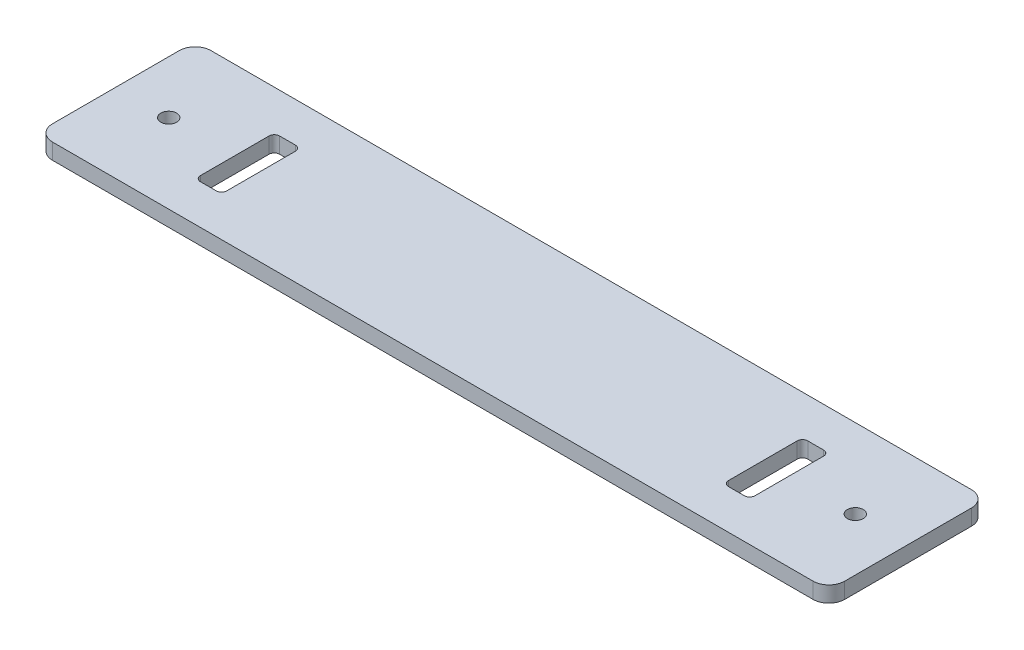
from build123d import *

# Parameters (mm, degrees)
SKETCH1_R           = 1.5
BOSS_EXTRUDE1_DEPTH = 3


with BuildPart() as part:
    # Sketch1 → Boss-Extrude1 (new body)
    with BuildSketch(Plane(origin=(0, 0, 0), x_dir=(1, 0, 0), z_dir=(0, 1, 0))):
        with BuildLine():
            Line((72, 15), (-72, 15))
            ThreePointArc((-72, 15), (-74.121320344, 14.121320344), (-75, 12))
            Line((-75, 12), (-75, -12))
            ThreePointArc((-75, -12), (-74.121320344, -14.121320344), (-72, -15))
            Line((-72, -15), (72, -15))
            ThreePointArc((72, -15), (74.121320344, -14.121320344), (75, -12))
            Line((75, -12), (75, 12))
            ThreePointArc((75, 12), (74.121320344, 14.121320344), (72, 15))
        make_face()
        with Locations((65, 0)):
            Circle(SKETCH1_R, mode=Mode.SUBTRACT)
        with Locations((-65, 0)):
            Circle(SKETCH1_R, mode=Mode.SUBTRACT)
        with BuildLine():
            Line((51.5, -7.5), (48.5, -7.5))
            ThreePointArc((48.5, -7.5), (47.792893219, -7.207106781), (47.5, -6.5))
            Line((47.5, -6.5), (47.5, 6.5))
            ThreePointArc((47.5, 6.5), (47.792893219, 7.207106781), (48.5, 7.5))
            Line((48.5, 7.5), (51.5, 7.5))
            ThreePointArc((51.5, 7.5), (52.207106781, 7.207106781), (52.5, 6.5))
            Line((52.5, 6.5), (52.5, -6.5))
            ThreePointArc((52.5, -6.5), (52.207106781, -7.207106781), (51.5, -7.5))
        make_face(mode=Mode.SUBTRACT)
        with BuildLine():
            Line((-47.5, -6.5), (-47.5, 6.5))
            ThreePointArc((-47.5, 6.5), (-47.792893219, 7.207106781), (-48.5, 7.5))
            Line((-48.5, 7.5), (-51.5, 7.5))
            ThreePointArc((-51.5, 7.5), (-52.207106781, 7.207106781), (-52.5, 6.5))
            Line((-52.5, 6.5), (-52.5, -6.5))
            ThreePointArc((-52.5, -6.5), (-52.207106781, -7.207106781), (-51.5, -7.5))
            Line((-51.5, -7.5), (-48.5, -7.5))
            ThreePointArc((-48.5, -7.5), (-47.792893219, -7.207106781), (-47.5, -6.5))
        make_face(mode=Mode.SUBTRACT)
    extrude(amount=BOSS_EXTRUDE1_DEPTH)


solid = part.part
